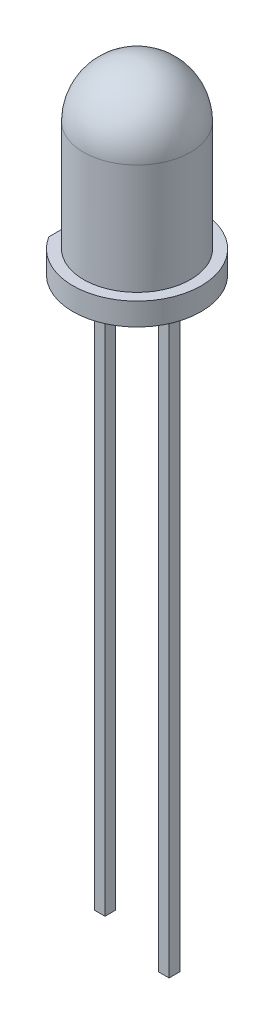
from build123d import *

# Parameters (mm, degrees)
SKETCH2_W           = 3.02065634
SKETCH2_H           = 7.518324789
CUT_EXTRUDE1_DEPTH  = 10
SKETCH3_W           = 0.5
SKETCH3_H           = 0.5
BOSS_EXTRUDE1_DEPTH = 27.5
SKETCH4_W           = 5.267687
SKETCH4_H           = 3.125919431
CUT_EXTRUDE2_DEPTH  = 13.75


with BuildPart() as part:
    # Sketch1 → Revolve1 (revolve)
    with BuildSketch(Plane.XY):
        with BuildLine():
            Line((0, 0), (3, 0))
            Line((3, 0), (3, 1.05))
            Line((3, 1.05), (2.5, 1.05))
            Line((2.5, 1.05), (2.5, 6.21))
            ThreePointArc((2.5, 6.21), (1.767766953, 7.977766953), (0, 8.71))
            Line((0, 8.71), (0, 6.21))
            Line((0, 6.21), (0, 0))
        make_face()
    revolve(axis=Axis((0, 6.21, 0), (0, -1, 0)))

    # Sketch2 → Cut-Extrude1 (cut)
    with BuildSketch(Plane.XZ):
        with Locations((-4.06032817, -1.07166668)):
            Rectangle(SKETCH2_W, SKETCH2_H)
    extrude(amount=-CUT_EXTRUDE1_DEPTH, mode=Mode.SUBTRACT)

    # Sketch3 → Boss-Extrude1 (add)
    with BuildSketch(Plane.XZ):
        with Locations((-1.5, 0)):
            Rectangle(SKETCH3_W, SKETCH3_H)
        with Locations((1.5, 0)):
            Rectangle(SKETCH3_W, SKETCH3_H)
    extrude(amount=BOSS_EXTRUDE1_DEPTH)

    # Sketch4 → Cut-Extrude2 (cut, symmetric)
    with BuildSketch(Plane.XY):
        with Locations((-2.6338435, -28.062959715)):
            Rectangle(SKETCH4_W, SKETCH4_H)
    extrude(amount=CUT_EXTRUDE2_DEPTH, both=True, mode=Mode.SUBTRACT)


solid = part.part
